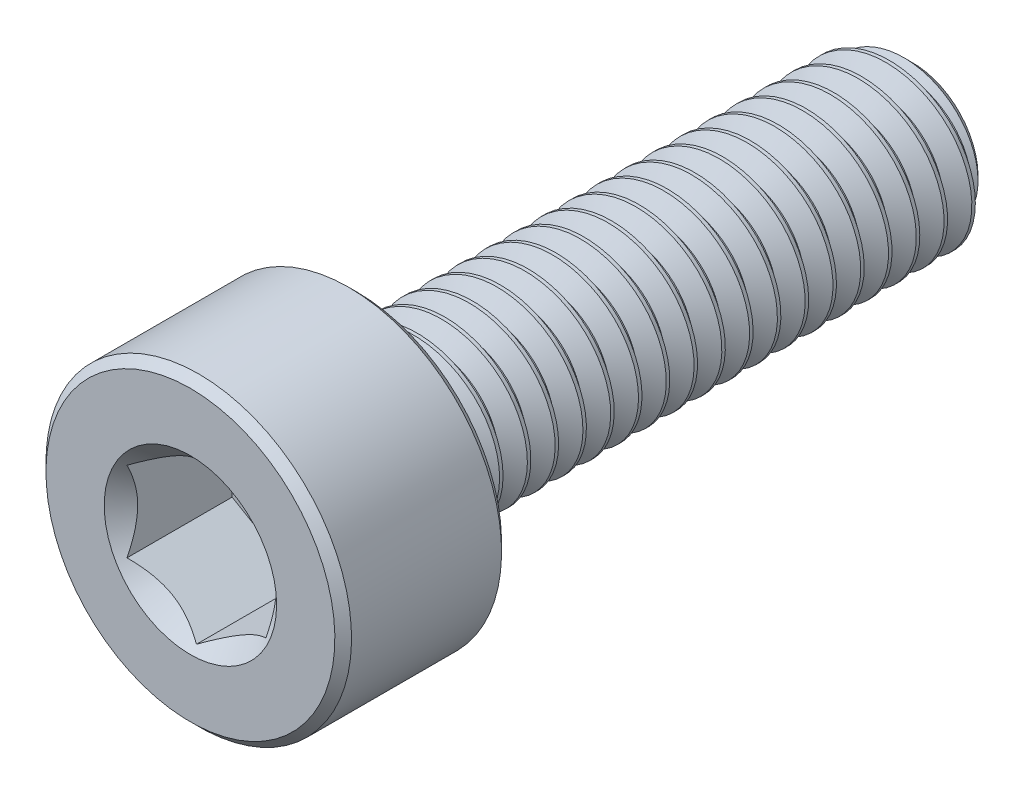
from build123d import *

# Parameters (mm, degrees)
CUT_EXTRUDE1_DEPTH     = 2
SKETCH4_R              = 1.5516288484471188
CUT_EXTRUDE2_DEPTH     = 1.5
CUT_EXTRUDE2_DRAFT     = -45.0000000000001
SPLIT1_SURFACE_1_BACK  = 16.149
SPLIT1_SURFACE_1_DEPTH = 32.298
SPLIT1_SURFACE_2_BACK  = 16.149
SPLIT1_SURFACE_2_DEPTH = 32.298
CUT_SWEEP1_PITCH       = 0.5000000000000041
CUT_SWEEP1_HEIGHT      = 10.500000000000007
CUT_SWEEP1_RADIUS      = 1.5000000000000002
CUT_SWEEP1_START_ANGLE = 89.99999999999983


with BuildPart() as part:
    # Sketch2 → Revolve1 (revolve)
    with BuildSketch(Plane(origin=(0, 0, 0), x_dir=(0, 0, -1), z_dir=(1, 0, 0))):
        with BuildLine():
            Line((-6.5, 0), (-6.5, 2.6))
            Line((-6.5, 2.6), (-6.35, 2.75))
            Line((-6.35, 2.75), (-3.6499999999999995, 2.75))
            Line((-3.6499999999999995, 2.75), (-3.4999999999999996, 2.6))
            Line((-3.4999999999999996, 2.6), (-3.4999999999999996, 1.6500000000000006))
            ThreePointArc((-3.4999999999999996, 1.6500000000000006), (-3.4560660171779816, 1.5439339828220184), (-3.349999999999999, 1.5000000000000009))
            Line((-3.349999999999999, 1.5000000000000009), (6.175240473580832, 1.5))
            Line((6.175240473580832, 1.5), (6.5, 1.1752404735808353))
            Line((6.5, 1.1752404735808353), (6.5, 0))
            Line((6.5, 0), (-6.5, 0))
        make_face()
    revolve(axis=Axis((0, 0, -6.5), (0, 0, 1)))

    # Sketch3 → Cut-Extrude1 (cut)
    with BuildSketch(Plane.XY.offset(6.5)):
        Polygon((1.25, -0.7216878364870324), (1.25, 0.7216878364870322), (-3.1e-16, 1.4433756729740643), (-1.2499999999999998, 0.7216878364870319), (-1.2499999999999998, -0.7216878364870324), (7.6e-16, -1.4433756729740648), align=None)
    extrude(amount=-CUT_EXTRUDE1_DEPTH, mode=Mode.SUBTRACT)


with BuildPart() as cut_extrude2_tool:
    # Sketch4 → Cut-Extrude2 (with draft: the straight prism first)
    with BuildSketch(Plane.XY.offset(6.5)):
        Circle(SKETCH4_R)
    extrude(amount=-CUT_EXTRUDE2_DEPTH)
    # Cut-Extrude2: the draft: its side faces are tilted about the plane it starts from
    cut_extrude2_sides = [cut_extrude2_tool.faces().sort_by_distance(p)[0] for p in [
        (-1.551628848, 0, 5.75),
    ]]
    draft(cut_extrude2_sides, Plane.XY.offset(6.5), CUT_EXTRUDE2_DRAFT)


with BuildPart() as part_1:
    add(part.part)

    # Cut-Extrude2: cut by cut_extrude2_tool
    add(cut_extrude2_tool.part, mode=Mode.SUBTRACT)


with BuildPart() as body_2:
    # Split1: the piece behind the surface
    add(part_1.part)
    # Split1 surface: a surface, the sketch's curves swept straight by 32.298 mm
    with BuildLine(Plane(origin=(0, 0, 0), x_dir=(0, 0, -1), z_dir=(1, 0, 0)).offset(-SPLIT1_SURFACE_1_BACK), mode=Mode.PRIVATE) as split1_surface_1_path:
        Line((-3.3499999999999996, -2.75), (-3.3499999999999996, 2.75))
    split1_surface_1 = Shell.extrude(split1_surface_1_path.wire(), (1 * SPLIT1_SURFACE_1_DEPTH, 0 * SPLIT1_SURFACE_1_DEPTH, 0 * SPLIT1_SURFACE_1_DEPTH))
    split(bisect_by=split1_surface_1, keep=Keep.BOTTOM)

    # Cut-Sweep1: sweep along a helix
    with BuildLine() as cut_sweep1_path:
        add(Helix(CUT_SWEEP1_PITCH, CUT_SWEEP1_HEIGHT, CUT_SWEEP1_RADIUS, center=(0, 0, -6.5), direction=(0, 0, 1), mode=Mode.PRIVATE).rotate(Axis((0, 0, -6.5), (0, 0, 1)), CUT_SWEEP1_START_ANGLE))
    # Sketch7 → Cut-Sweep1 (sweep, cut)
    with BuildSketch(Plane(origin=(0, 0, 0), x_dir=(0, 0, -1), z_dir=(1, 0, 0))):
        Polygon((6.484374999999984, 1.5270632938682633), (6.953125000000012, 1.5270632938682633), (6.75, 1.1752404735808353), (6.6875, 1.1752404735808353), align=None)
    sweep(path=cut_sweep1_path.line, is_frenet=True, mode=Mode.SUBTRACT)


with BuildPart() as part_2:
    add(part_1.part)

    # Split1: split by a surface, the side it looks to stays
    # Split1 surface: a surface, the sketch's curves swept straight by 32.298 mm
    with BuildLine(Plane(origin=(0, 0, 0), x_dir=(0, 0, -1), z_dir=(1, 0, 0)).offset(-SPLIT1_SURFACE_2_BACK), mode=Mode.PRIVATE) as split1_surface_2_path:
        Line((-3.3499999999999996, -2.75), (-3.3499999999999996, 2.75))
    split1_surface_2 = Shell.extrude(split1_surface_2_path.wire(), (1 * SPLIT1_SURFACE_2_DEPTH, 0 * SPLIT1_SURFACE_2_DEPTH, 0 * SPLIT1_SURFACE_2_DEPTH))
    split(bisect_by=split1_surface_2, keep=Keep.TOP)

    add(body_2.part)  # Revolve2 merges body 2
    # Sketch8 → Revolve2 (revolve)
    with BuildSketch(Plane(origin=(0, 0, 0), x_dir=(0, 0, -1), z_dir=(1, 0, 0))):
        Polygon((-3.4999999999999996, 4e-17), (-3.4999999999999996, 1.5), (-3.3499999999999996, 1.5), (-2.4839745962155515, 1.8e-16), align=None)
    revolve(axis=Axis((0, 1.8e-16, 2.4839745962155515), (0, -1.4e-16, 1)))


solid = part_2.part
